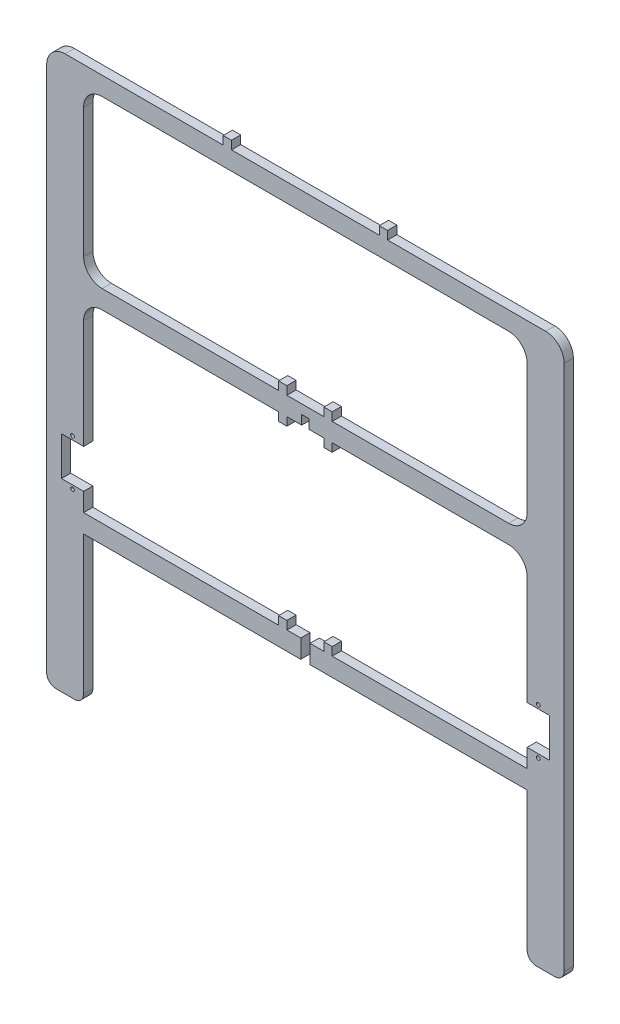
from build123d import *

# Parameters (mm, degrees)
SKETCH1_R           = 1
SKETCH1_W           = 4.5
SKETCH1_H           = 4.5
SKETCH1_W_2         = 2
SKETCH1_H_2         = 5
BOSS_EXTRUDE1_DEPTH = 2.5


with BuildPart() as part:
    # Sketch1 → Boss-Extrude1 (new body, symmetric)
    with BuildSketch(Plane.XY):
        with BuildLine():
            Line((-120, -79), (-120, -20))
            ThreePointArc((-120, -20), (-117.071067812, -12.928932188), (-110, -10))
            Line((-110, -10), (-14.5, -10))
            Line((-14.5, -10), (-10, -10))
            Line((-10, -10), (-2, -10))
            Line((-2, -10), (-2, -5))
            Line((-2, -5), (-2, 0))
            Line((-2, 0), (-10, 0))
            Line((-10, 0), (-14.5, 0))
            Line((-14.5, 0), (-110, 0))
            ThreePointArc((-110, 0), (-117.071067812, 2.928932188), (-120, 10))
            Line((-120, 10), (-120, 80))
            ThreePointArc((-120, 80), (-117.071067812, 87.071067812), (-110, 90))
            Line((-110, 90), (0, 90))
            Line((0, 90), (0, 100))
            Line((0, 100), (-40, 100))
            Line((-40, 100), (-44.5, 100))
            Line((-44.5, 100), (-120, 100))
            Line((-120, 100), (-130, 100))
            ThreePointArc((-130, 100), (-137.071067812, 97.071067812), (-140, 90))
            Line((-140, 90), (-140, -195))
            ThreePointArc((-140, -195), (-138.535533906, -198.535533906), (-135, -200))
            Line((-135, -200), (-125, -200))
            ThreePointArc((-125, -200), (-121.464466094, -198.535533906), (-120, -195))
            Line((-120, -195), (-120, -120))
            Line((-120, -120), (-120, -110))
            Line((-120, -110), (-120, -100))
            Line((-120, -100), (-132, -100))
            Line((-132, -100), (-132, -79))
            Line((-132, -79), (-120, -79))
        make_face()
        with Locations((-126, -102)):
            Circle(SKETCH1_R, mode=Mode.SUBTRACT)
        with Locations((-126, -77)):
            Circle(SKETCH1_R, mode=Mode.SUBTRACT)
        with Locations((-42.25, 102.25)):
            Rectangle(SKETCH1_W, SKETCH1_H)
        with Locations((-12.25, 2.25)):
            Rectangle(SKETCH1_W, SKETCH1_H)
        with Locations((-12.25, -12.25)):
            Rectangle(SKETCH1_W, SKETCH1_H)
        with Locations((-1, -2.5)):
            Rectangle(SKETCH1_W_2, SKETCH1_H_2)
        Polygon((-14.5, -110), (-120, -110), (-120, -120), (-2.5, -120), (-2.5, -110), (-10, -110), align=None)
        with Locations((-12.25, -107.75)):
            Rectangle(SKETCH1_W, SKETCH1_H)
    extrude(amount=BOSS_EXTRUDE1_DEPTH, both=True)

    # Mirror1: part across plane


with BuildPart() as part_1:
    add(part.part)
    add(part.part.mirror(Plane(origin=(0, 0, 0), x_dir=(0, 0, 1), z_dir=(1, 0, 0))))


solid = part_1.part
